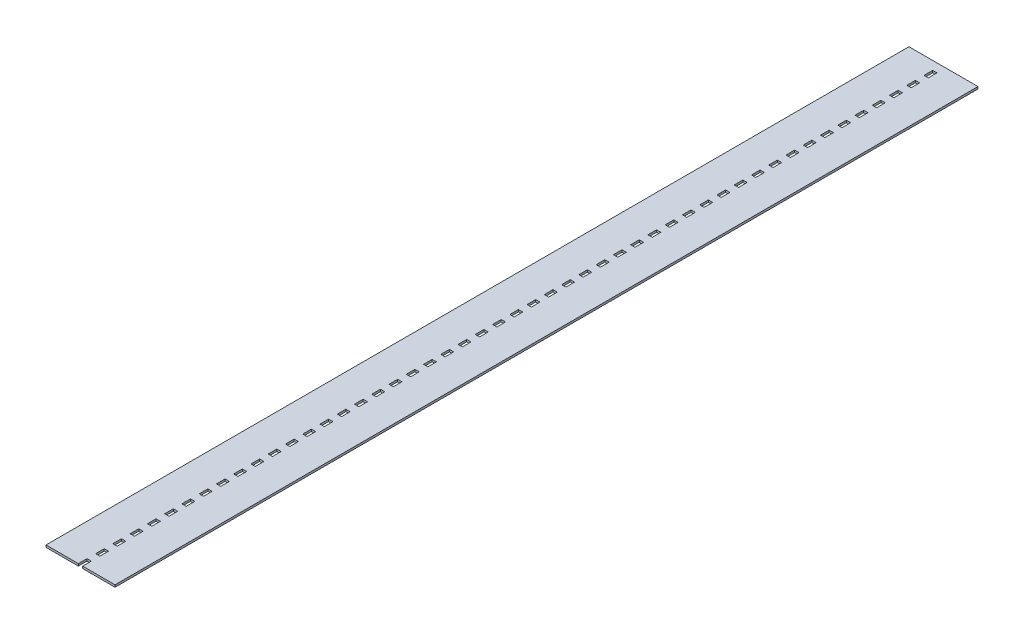
from build123d import *

# Parameters (mm, degrees)
SKETCH1_W           = 50
SKETCH1_H           = 100
BOSS_EXTRUDE1_DEPTH = 25


with BuildPart() as part:
    # Sketch1 → Boss-Extrude1 (new body)
    with BuildSketch(Plane(origin=(0, 0, 0), x_dir=(1, 0, 0), z_dir=(0, 1, 0))):
        Polygon((-90.554666691, 9937.601669113), (-465.554666691, 9937.601669113), (-465.554666691, -62.398330887), (-90.554666691, -62.398330887), (-90.554666691, 37.601669113), (-40.554666691, 37.601669113), (-40.554666691, -62.398330887), (334.445333309, -62.398330887), (334.445333309, 9937.601669113), (-40.554666691, 9937.601669113), align=None)
        with Locations((-65.554666691, 187.601669113)):
            Rectangle(SKETCH1_W, SKETCH1_H, mode=Mode.SUBTRACT)
        with Locations((-65.554666691, 387.601669113)):
            Rectangle(SKETCH1_W, SKETCH1_H, mode=Mode.SUBTRACT)
        with Locations((-65.554666691, 587.601669113)):
            Rectangle(SKETCH1_W, SKETCH1_H, mode=Mode.SUBTRACT)
        with Locations((-65.554666691, 787.601669113)):
            Rectangle(SKETCH1_W, SKETCH1_H, mode=Mode.SUBTRACT)
        with Locations((-65.554666691, 987.601669113)):
            Rectangle(SKETCH1_W, SKETCH1_H, mode=Mode.SUBTRACT)
        with Locations((-65.554666691, 1187.601669113)):
            Rectangle(SKETCH1_W, SKETCH1_H, mode=Mode.SUBTRACT)
        with Locations((-65.554666691, 1387.601669113)):
            Rectangle(SKETCH1_W, SKETCH1_H, mode=Mode.SUBTRACT)
        with Locations((-65.554666691, 1587.601669113)):
            Rectangle(SKETCH1_W, SKETCH1_H, mode=Mode.SUBTRACT)
        with Locations((-65.554666691, 1787.601669113)):
            Rectangle(SKETCH1_W, SKETCH1_H, mode=Mode.SUBTRACT)
        with Locations((-65.554666691, 1987.601669113)):
            Rectangle(SKETCH1_W, SKETCH1_H, mode=Mode.SUBTRACT)
        with Locations((-65.554666691, 2187.601669113)):
            Rectangle(SKETCH1_W, SKETCH1_H, mode=Mode.SUBTRACT)
        with Locations((-65.554666691, 2387.601669113)):
            Rectangle(SKETCH1_W, SKETCH1_H, mode=Mode.SUBTRACT)
        with Locations((-65.554666691, 2587.601669113)):
            Rectangle(SKETCH1_W, SKETCH1_H, mode=Mode.SUBTRACT)
        with Locations((-65.554666691, 2787.601669113)):
            Rectangle(SKETCH1_W, SKETCH1_H, mode=Mode.SUBTRACT)
        with Locations((-65.554666691, 2987.601669113)):
            Rectangle(SKETCH1_W, SKETCH1_H, mode=Mode.SUBTRACT)
        with Locations((-65.554666691, 3187.601669113)):
            Rectangle(SKETCH1_W, SKETCH1_H, mode=Mode.SUBTRACT)
        with Locations((-65.554666691, 3387.601669113)):
            Rectangle(SKETCH1_W, SKETCH1_H, mode=Mode.SUBTRACT)
        with Locations((-65.554666691, 3587.601669113)):
            Rectangle(SKETCH1_W, SKETCH1_H, mode=Mode.SUBTRACT)
        with Locations((-65.554666691, 3787.601669113)):
            Rectangle(SKETCH1_W, SKETCH1_H, mode=Mode.SUBTRACT)
        with Locations((-65.554666691, 3987.601669113)):
            Rectangle(SKETCH1_W, SKETCH1_H, mode=Mode.SUBTRACT)
        with Locations((-65.554666691, 4187.601669113)):
            Rectangle(SKETCH1_W, SKETCH1_H, mode=Mode.SUBTRACT)
        with Locations((-65.554666691, 4387.601669113)):
            Rectangle(SKETCH1_W, SKETCH1_H, mode=Mode.SUBTRACT)
        with Locations((-65.554666691, 4587.601669113)):
            Rectangle(SKETCH1_W, SKETCH1_H, mode=Mode.SUBTRACT)
        with Locations((-65.554666691, 4787.601669113)):
            Rectangle(SKETCH1_W, SKETCH1_H, mode=Mode.SUBTRACT)
        with Locations((-65.554666691, 5387.601669113)):
            Rectangle(SKETCH1_W, SKETCH1_H, mode=Mode.SUBTRACT)
        with Locations((-65.554666691, 5587.601669113)):
            Rectangle(SKETCH1_W, SKETCH1_H, mode=Mode.SUBTRACT)
        with Locations((-65.554666691, 5787.601669113)):
            Rectangle(SKETCH1_W, SKETCH1_H, mode=Mode.SUBTRACT)
        with Locations((-65.554666691, 5987.601669113)):
            Rectangle(SKETCH1_W, SKETCH1_H, mode=Mode.SUBTRACT)
        with Locations((-65.554666691, 6187.601669113)):
            Rectangle(SKETCH1_W, SKETCH1_H, mode=Mode.SUBTRACT)
        with Locations((-65.554666691, 6387.601669113)):
            Rectangle(SKETCH1_W, SKETCH1_H, mode=Mode.SUBTRACT)
        with Locations((-65.554666691, 6587.601669113)):
            Rectangle(SKETCH1_W, SKETCH1_H, mode=Mode.SUBTRACT)
        with Locations((-65.554666691, 6787.601669113)):
            Rectangle(SKETCH1_W, SKETCH1_H, mode=Mode.SUBTRACT)
        with Locations((-65.554666691, 6987.601669113)):
            Rectangle(SKETCH1_W, SKETCH1_H, mode=Mode.SUBTRACT)
        with Locations((-65.554666691, 7187.601669113)):
            Rectangle(SKETCH1_W, SKETCH1_H, mode=Mode.SUBTRACT)
        with Locations((-65.554666691, 7387.601669113)):
            Rectangle(SKETCH1_W, SKETCH1_H, mode=Mode.SUBTRACT)
        with Locations((-65.554666691, 7587.601669113)):
            Rectangle(SKETCH1_W, SKETCH1_H, mode=Mode.SUBTRACT)
        with Locations((-65.554666691, 7787.601669113)):
            Rectangle(SKETCH1_W, SKETCH1_H, mode=Mode.SUBTRACT)
        with Locations((-65.554666691, 7987.601669113)):
            Rectangle(SKETCH1_W, SKETCH1_H, mode=Mode.SUBTRACT)
        with Locations((-65.554666691, 8187.601669113)):
            Rectangle(SKETCH1_W, SKETCH1_H, mode=Mode.SUBTRACT)
        with Locations((-65.554666691, 8387.601669113)):
            Rectangle(SKETCH1_W, SKETCH1_H, mode=Mode.SUBTRACT)
        with Locations((-65.554666691, 8587.601669113)):
            Rectangle(SKETCH1_W, SKETCH1_H, mode=Mode.SUBTRACT)
        with Locations((-65.554666691, 8787.601669113)):
            Rectangle(SKETCH1_W, SKETCH1_H, mode=Mode.SUBTRACT)
        with Locations((-65.554666691, 8987.601669113)):
            Rectangle(SKETCH1_W, SKETCH1_H, mode=Mode.SUBTRACT)
        with Locations((-65.554666691, 9187.601669113)):
            Rectangle(SKETCH1_W, SKETCH1_H, mode=Mode.SUBTRACT)
        with Locations((-65.554666691, 9387.601669113)):
            Rectangle(SKETCH1_W, SKETCH1_H, mode=Mode.SUBTRACT)
        with Locations((-65.554666691, 9587.601669113)):
            Rectangle(SKETCH1_W, SKETCH1_H, mode=Mode.SUBTRACT)
        with Locations((-65.554666691, 9787.601669113)):
            Rectangle(SKETCH1_W, SKETCH1_H, mode=Mode.SUBTRACT)
        with Locations((-65.554666691, 4987.601669113)):
            Rectangle(SKETCH1_W, SKETCH1_H, mode=Mode.SUBTRACT)
        with Locations((-65.554666691, 5187.601669113)):
            Rectangle(SKETCH1_W, SKETCH1_H, mode=Mode.SUBTRACT)
    extrude(amount=BOSS_EXTRUDE1_DEPTH)


solid = part.part
